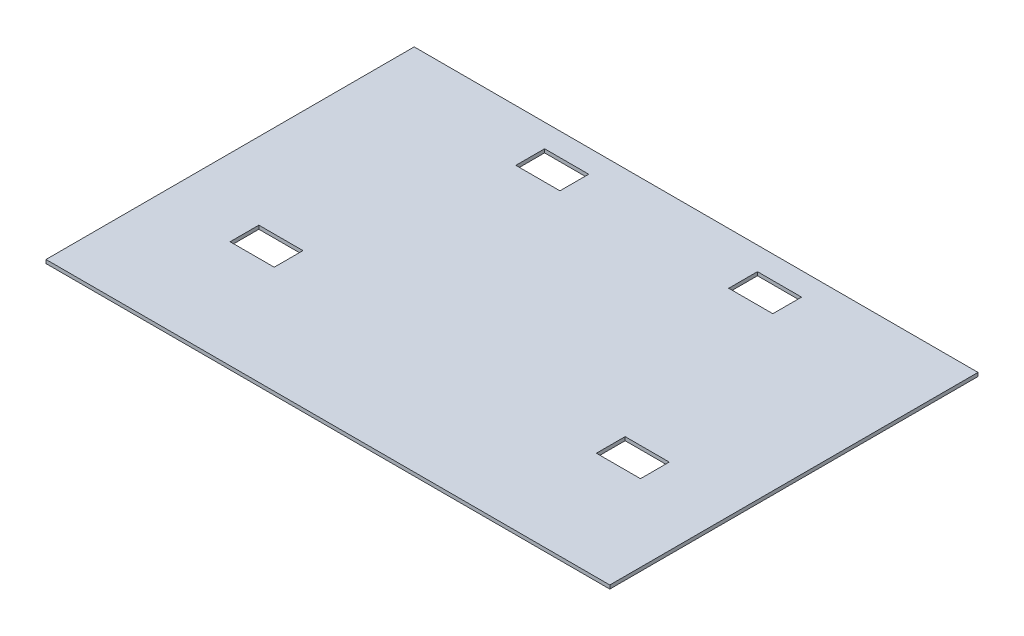
from build123d import *

# Parameters (mm, degrees)
SKETCH1_W           = 1866.9
SKETCH1_H           = 1219.2
BOSS_EXTRUDE1_DEPTH = 5.953125
SKETCH4_W           = 146.05
SKETCH4_H           = 95.25
CUT_EXTRUDE3_DEPTH  = 12.90625


with BuildPart() as part:
    # Sketch1 → Boss-Extrude1 (new body, symmetric)
    with BuildSketch(Plane(origin=(0, 0, 0), x_dir=(1, 0, 0), z_dir=(0, 1, 0))):
        Rectangle(SKETCH1_W, SKETCH1_H)
    extrude(amount=BOSS_EXTRUDE1_DEPTH, both=True)

    # Sketch4 → Cut-Extrude3 (cut, through all)
    with BuildSketch(Plane.XZ.offset(5.953125)):
        with Locations((352.425, -485.775)):
            Rectangle(SKETCH4_W, SKETCH4_H)
        with Locations((-352.425, -485.775)):
            Rectangle(SKETCH4_W, SKETCH4_H)
        with Locations((-606.425, 206.375)):
            Rectangle(SKETCH4_W, SKETCH4_H)
        with Locations((606.425, 206.375)):
            Rectangle(SKETCH4_W, SKETCH4_H)
    extrude(amount=-CUT_EXTRUDE3_DEPTH, mode=Mode.SUBTRACT)


solid = part.part
